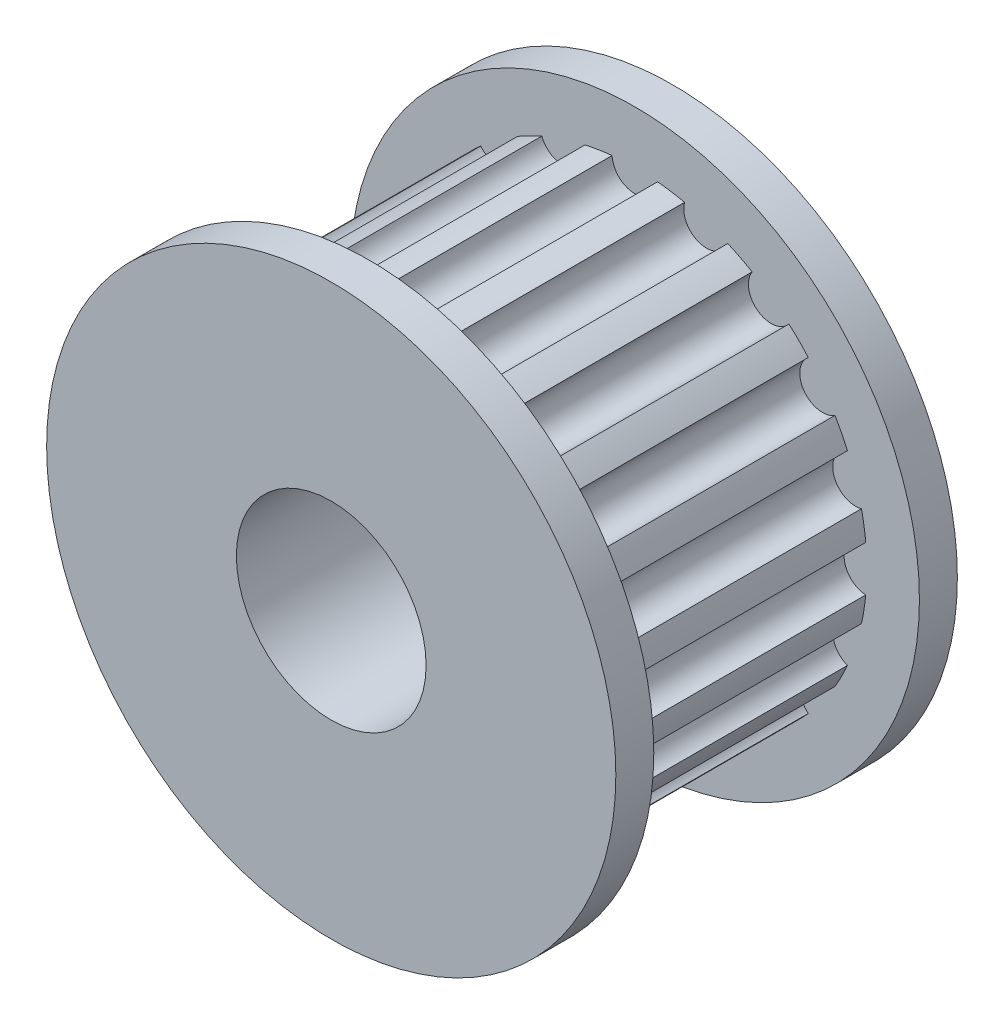
from build123d import *

# Parameters (mm, degrees)
SKETCH_1_R               = 7.5
EXTRUDE_1_DEPTH          = 0.5
SKETCH_2_R               = 6.115
EXTRUDE_2_DEPTH          = 7
CUT_EXTRUDE_3_DEPTH      = 7
SKETCH_3_R               = 7.5
EXTRUDE_3_DEPTH          = 1
SKETCH_6_R               = 2.5
CUT_EXTRUDE_2_DEPTH      = 10
PATTERN_CIRCULAR_2_COUNT = 20


with BuildPart() as part:
    # 草圖1 → 填料-伸長1 (new body, symmetric)
    with BuildSketch(Plane.XY):
        Circle(SKETCH_1_R)
    extrude(amount=EXTRUDE_1_DEPTH, both=True)

    # 草圖2 → 填料-伸長2 (add)
    with BuildSketch(Plane.XY.offset(0.5)):
        Circle(SKETCH_2_R)
    extrude(amount=EXTRUDE_2_DEPTH)

    # 草圖7 → 除料-伸長3 (cut)
    with BuildSketch(Plane.XY.offset(7.5)):
        with BuildLine():
            ThreePointArc((-0.599277509, 6.085564186), (0, 5.515), (0.599277509, 6.085564186))
            ThreePointArc((0.599277509, 6.085564186), (0, 6.115), (-0.599277509, 6.085564186))
        make_face()
    cut_extrude_3 = extrude(amount=-CUT_EXTRUDE_3_DEPTH, mode=Mode.SUBTRACT)

    # 草圖3 → 填料-伸長3 (add)
    with BuildSketch(Plane.XY.offset(7.5)):
        Circle(SKETCH_3_R)
    extrude(amount=EXTRUDE_3_DEPTH)

    # 草圖6 → 除料-伸長2 (cut, through all)
    with BuildSketch(Plane(origin=(0, 0, -0.5), x_dir=(-1, 0, 0), z_dir=(0, 0, -1))):
        Circle(SKETCH_6_R)
    extrude(amount=-CUT_EXTRUDE_2_DEPTH, mode=Mode.SUBTRACT)

    # 環狀複製排列2: 除料-伸長3 ×20 about axis
    pattern_circular_2_axis = Axis((0, 0, 0), (0, 0, 1))
    for i in range(1, PATTERN_CIRCULAR_2_COUNT):
        add(cut_extrude_3.rotate(pattern_circular_2_axis, i * 360 / PATTERN_CIRCULAR_2_COUNT), mode=Mode.SUBTRACT)


solid = part.part
